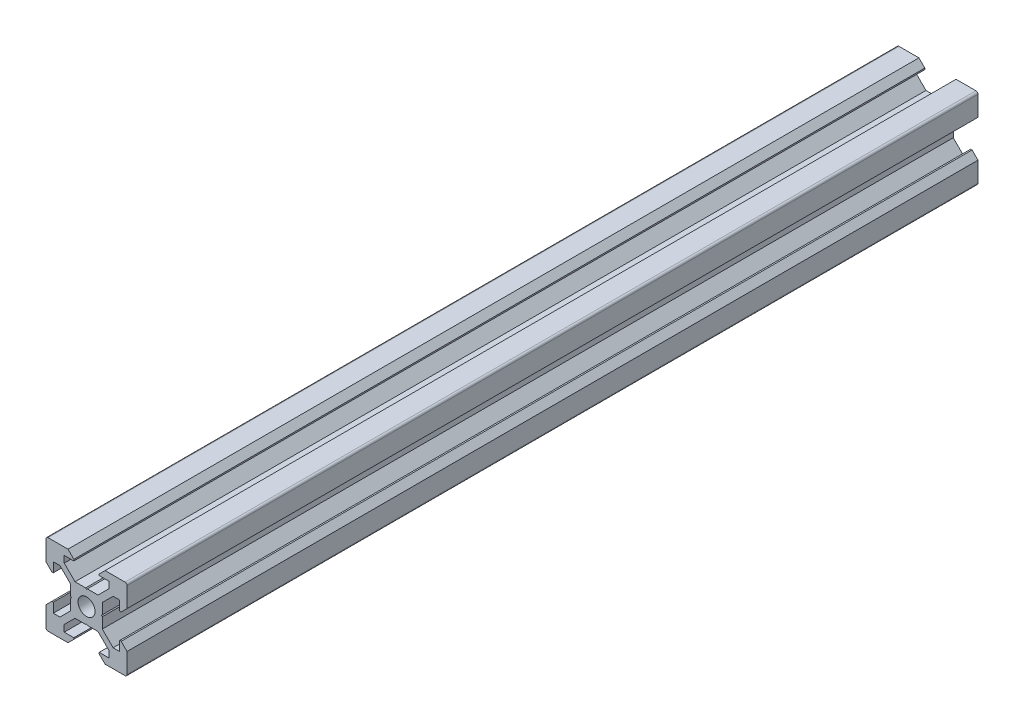
from build123d import *

# Parameters (mm, degrees)
SKETCH1_R           = 2.1
BOSS_EXTRUDE1_DEPTH = 210


with BuildPart() as part:
    # Sketch1 → Boss-Extrude1 (new body)
    with BuildSketch(Plane.XY):
        with BuildLine():
            Line((4.58, -10), (9.5, -10))
            ThreePointArc((9.5, -10), (9.853553391, -9.853553391), (10, -9.5))
            Line((10, -9.5), (10, -4.58))
            Line((10, -4.58), (8.545, -3.125))
            Line((8.545, -3.125), (8.2, -3.125))
            Line((8.2, -3.125), (8.2, -5.5))
            Line((8.2, -5.5), (6.560660172, -5.5))
            Line((6.560660172, -5.5), (3.9, -2.839339828))
            Line((3.9, -2.839339828), (3.9, -0.21))
            Line((3.9, -0.21), (3.69, 0))
            Line((3.69, 0), (3.9, 0.21))
            Line((3.9, 0.21), (3.9, 2.839339828))
            Line((3.9, 2.839339828), (6.560660172, 5.5))
            Line((6.560660172, 5.5), (8.2, 5.5))
            Line((8.2, 5.5), (8.2, 3.125))
            Line((8.2, 3.125), (8.545, 3.125))
            Line((8.545, 3.125), (10, 4.58))
            Line((10, 4.58), (10, 9.5))
            ThreePointArc((10, 9.5), (9.853553391, 9.853553391), (9.5, 10))
            Line((9.5, 10), (4.58, 10))
            Line((4.58, 10), (3.125, 8.545))
            Line((3.125, 8.545), (3.125, 8.2))
            Line((3.125, 8.2), (5.5, 8.2))
            Line((5.5, 8.2), (5.5, 6.560660172))
            Line((5.5, 6.560660172), (2.839339828, 3.9))
            Line((2.839339828, 3.9), (0.21, 3.9))
            Line((0.21, 3.9), (0, 3.69))
            Line((0, 3.69), (-0.21, 3.9))
            Line((-0.21, 3.9), (-2.839339828, 3.9))
            Line((-2.839339828, 3.9), (-5.5, 6.560660172))
            Line((-5.5, 6.560660172), (-5.5, 8.2))
            Line((-5.5, 8.2), (-3.125, 8.2))
            Line((-3.125, 8.2), (-3.125, 8.545))
            Line((-3.125, 8.545), (-4.58, 10))
            Line((-4.58, 10), (-9.5, 10))
            ThreePointArc((-9.5, 10), (-9.853553391, 9.853553391), (-10, 9.5))
            Line((-10, 9.5), (-10, 4.58))
            Line((-10, 4.58), (-8.545, 3.125))
            Line((-8.545, 3.125), (-8.2, 3.125))
            Line((-8.2, 3.125), (-8.2, 5.5))
            Line((-8.2, 5.5), (-6.560660172, 5.5))
            Line((-6.560660172, 5.5), (-3.9, 2.839339828))
            Line((-3.9, 2.839339828), (-3.9, 0.21))
            Line((-3.9, 0.21), (-3.69, 0))
            Line((-3.69, 0), (-3.9, -0.21))
            Line((-3.9, -0.21), (-3.9, -2.839339828))
            Line((-3.9, -2.839339828), (-6.560660172, -5.5))
            Line((-6.560660172, -5.5), (-8.2, -5.5))
            Line((-8.2, -5.5), (-8.2, -3.125))
            Line((-8.2, -3.125), (-8.545, -3.125))
            Line((-8.545, -3.125), (-10, -4.58))
            Line((-10, -4.58), (-10, -9.5))
            ThreePointArc((-10, -9.5), (-9.853553391, -9.853553391), (-9.5, -10))
            Line((-9.5, -10), (-4.58, -10))
            Line((-4.58, -10), (-3.125, -8.545))
            Line((-3.125, -8.545), (-3.125, -8.2))
            Line((-3.125, -8.2), (-5.5, -8.2))
            Line((-5.5, -8.2), (-5.5, -6.560660172))
            Line((-5.5, -6.560660172), (-2.839339828, -3.9))
            Line((-2.839339828, -3.9), (-0.21, -3.9))
            Line((-0.21, -3.9), (0, -3.69))
            Line((0, -3.69), (0.21, -3.9))
            Line((0.21, -3.9), (2.839339828, -3.9))
            Line((2.839339828, -3.9), (5.5, -6.560660172))
            Line((5.5, -6.560660172), (5.5, -8.2))
            Line((5.5, -8.2), (3.125, -8.2))
            Line((3.125, -8.2), (3.125, -8.545))
            Line((3.125, -8.545), (4.58, -10))
        make_face()
        Circle(SKETCH1_R, mode=Mode.SUBTRACT)
    extrude(amount=BOSS_EXTRUDE1_DEPTH)


solid = part.part
